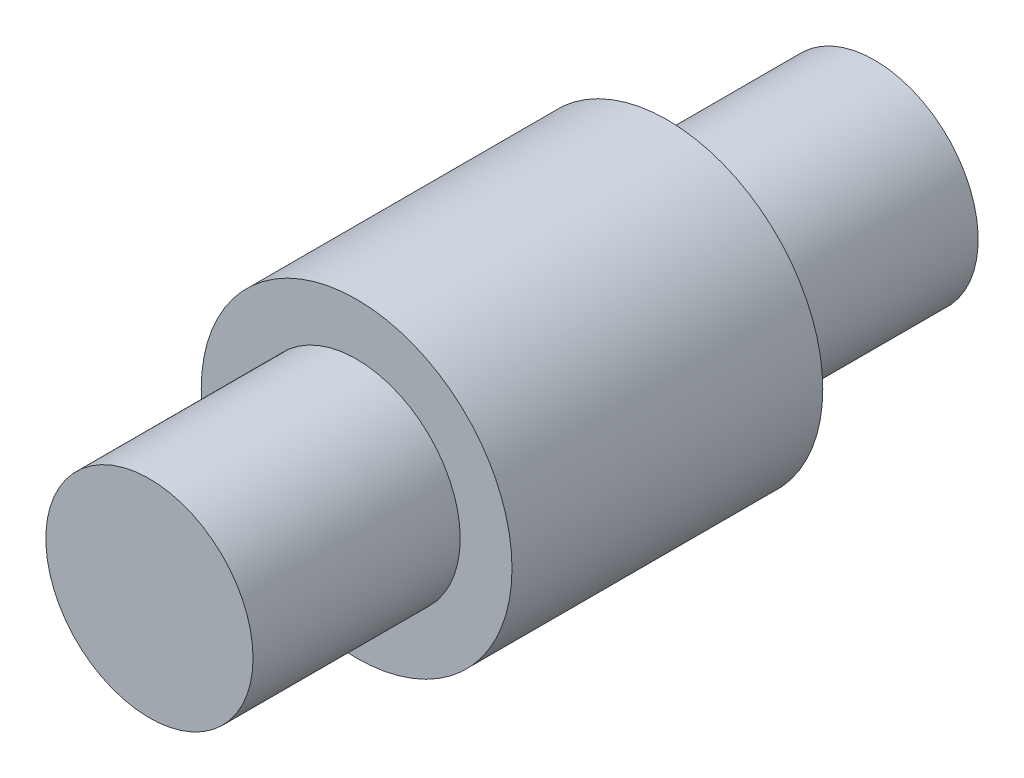
from build123d import *

# Parameters (mm, degrees)
SKETCH1_R           = 15
BOSS_EXTRUDE1_DEPTH = 15
SKETCH2_R           = 10
BOSS_EXTRUDE2_DEPTH = 20
BOSS_EXTRUDE3_START = 20
SKETCH3_R           = 10
BOSS_EXTRUDE3_DEPTH = 20


with BuildPart() as part:
    # Sketch1 → Boss-Extrude1 (new, symmetric)
    with BuildSketch(Plane.XY):
        Circle(SKETCH1_R)
    extrude(amount=BOSS_EXTRUDE1_DEPTH, both=True)

    # Sketch2 → Boss-Extrude2 (add)
    with BuildSketch(Plane.XY.offset(15)):
        Circle(SKETCH2_R)
    extrude(amount=BOSS_EXTRUDE2_DEPTH)

    # Sketch3 → Boss-Extrude3 (add)
    with BuildSketch(Plane(origin=(0, 0, -15), x_dir=(-1, 0, 0), z_dir=(0, 0, -1)).offset(BOSS_EXTRUDE3_START)):
        Circle(SKETCH3_R)
    extrude(amount=-BOSS_EXTRUDE3_DEPTH)


solid = part.part
